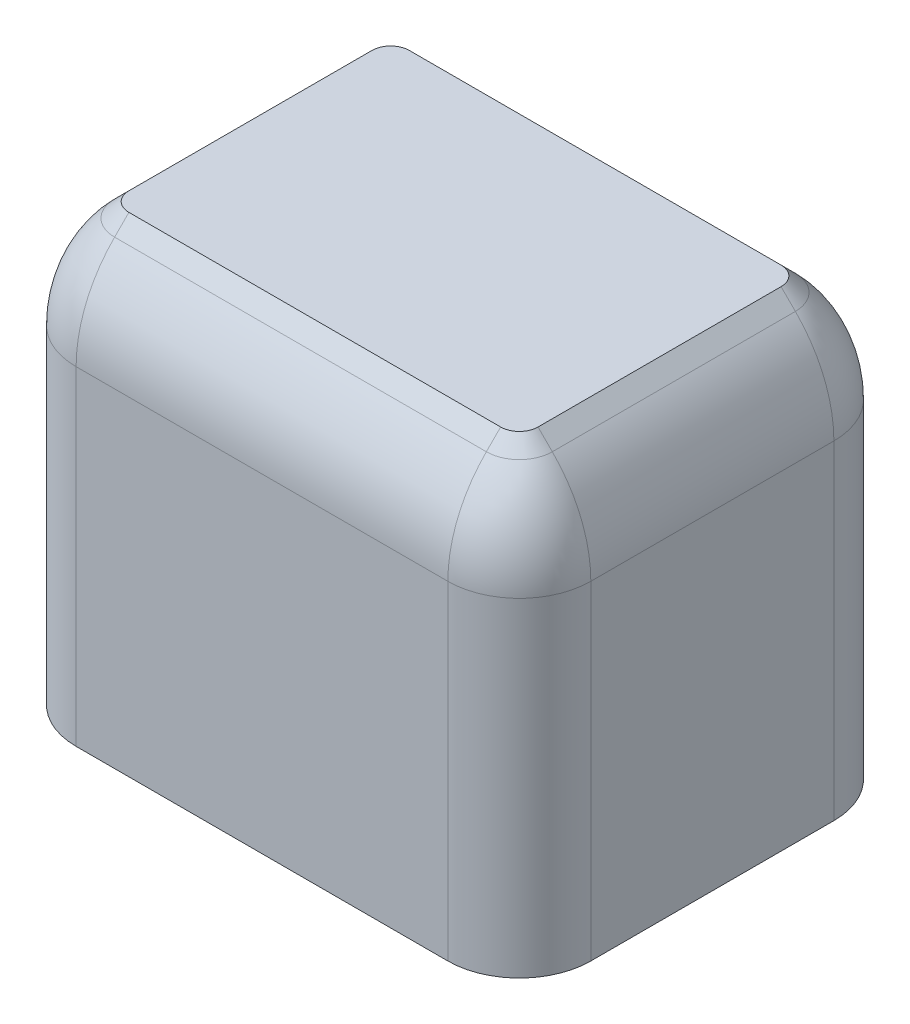
from build123d import *

# Parameters (mm, degrees)
SKETCH1_W           = 7.2
SKETCH1_H           = 5.4
STEM_HOUSING_DEPTH  = 4.5
SKETCH3_W           = 7.2
SKETCH3_H           = 5.4
BOSS_EXTRUDE2_DEPTH = 1.6
FILLET2_R           = 1


with BuildPart() as part:
    # Sketch1 → stem housing (new body)
    with BuildSketch(Plane(origin=(0, 0, 0), x_dir=(1, 0, 0), z_dir=(0, 1, 0))):
        Rectangle(SKETCH1_W, SKETCH1_H)
        with BuildLine():
            Line((-0.675, 0.975), (-0.675, 2.1))
            Line((-0.675, 2.1), (0.675, 2.1))
            Line((0.675, 2.1), (0.675, 0.975))
            ThreePointArc((0.675, 0.975), (0.762867966, 0.762867966), (0.975, 0.675))
            Line((0.975, 0.675), (2.15, 0.675))
            Line((2.15, 0.675), (2.15, -0.675))
            Line((2.15, -0.675), (0.975, -0.675))
            ThreePointArc((0.975, -0.675), (0.762867966, -0.762867966), (0.675, -0.975))
            Line((0.675, -0.975), (0.675, -2.1))
            Line((0.675, -2.1), (-0.675, -2.1))
            Line((-0.675, -2.1), (-0.675, -0.975))
            ThreePointArc((-0.675, -0.975), (-0.762867966, -0.762867966), (-0.975, -0.675))
            Line((-0.975, -0.675), (-2.15, -0.675))
            Line((-2.15, -0.675), (-2.15, 0.675))
            Line((-2.15, 0.675), (-0.975, 0.675))
            ThreePointArc((-0.975, 0.675), (-0.762867966, 0.762867966), (-0.675, 0.975))
        make_face(mode=Mode.SUBTRACT)
    extrude(amount=STEM_HOUSING_DEPTH)

    # Sketch3 → Boss-Extrude2 (add)
    with BuildSketch(Plane(origin=(0, 4.5, 0), x_dir=(1, 0, 0), z_dir=(0, 1, 0))):
        Rectangle(SKETCH3_W, SKETCH3_H)
    extrude(amount=BOSS_EXTRUDE2_DEPTH)

    # Fillet2
    fillet2_edges = [part.edges().sort_by_distance(p)[0] for p in [
        (-3.6, 3.05, 2.7),
        (-3.6, 3.05, -2.7),
        (3.6, 3.05, -2.7),
        (3.6, 3.05, 2.7),
    ]]
    fillet(fillet2_edges, radius=FILLET2_R)

    # Cut-Sweep1: sweep along a path in Sketch6
    with BuildLine(Plane(origin=(0, 6.1, 0), x_dir=(1, 0, 0), z_dir=(0, 1, 0))) as cut_sweep1_path:
        Line((-2.6, -2.7), (2.6, -2.7))
        ThreePointArc((2.6, -2.7), (3.307106781, -2.407106781), (3.6, -1.7))
        Line((3.6, -1.7), (3.6, 1.7))
        ThreePointArc((3.6, 1.7), (3.307106781, 2.407106781), (2.6, 2.7))
        Line((2.6, 2.7), (-2.6, 2.7))
        ThreePointArc((-2.6, 2.7), (-3.307106781, 2.407106781), (-3.6, 1.7))
        Line((-3.6, 1.7), (-3.6, -1.7))
        ThreePointArc((-3.6, -1.7), (-3.307106781, -2.407106781), (-2.6, -2.7))
    # Sketch4 → Cut-Sweep1 (sweep, cut)
    with BuildSketch(Plane.XY):
        with BuildLine():
            Line((-2.861522369, 6.1), (-3.061522369, 5.9))
            ThreePointArc((-3.061522369, 5.9), (-3.460054223, 5.30355493), (-3.6, 4.6))
            Line((-3.6, 4.6), (-3.6, 6.1))
            Line((-3.6, 6.1), (-2.861522369, 6.1))
        make_face()
    sweep(path=cut_sweep1_path.line, mode=Mode.SUBTRACT)


solid = part.part
